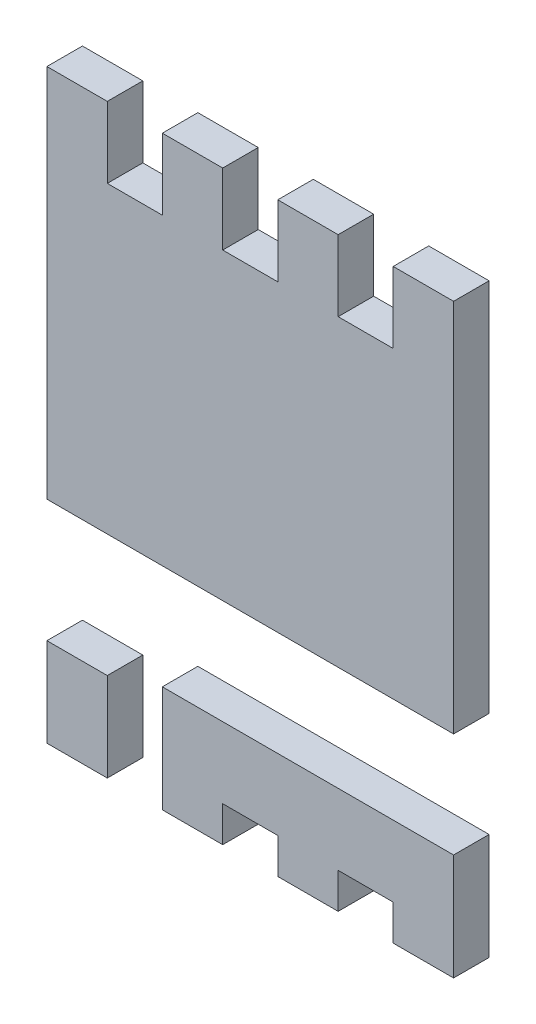
from build123d import *

# Parameters (mm, degrees)
EXTRUDE_1_DEPTH   = 0.2
EXTRUDE_1_2_DEPTH = 0.2
SKETCH_2_W        = 0.34
SKETCH_2_H        = 0.5
EXTRUDE_1_3_DEPTH = 0.2


with BuildPart() as part:
    # Эскиз2 → Бобышка-Вытянуть1 (new body)
    with BuildSketch(Plane.XY):
        Polygon((-1.145, 1.65), (-1.145, -0.46), (1.145, -0.46), (1.145, 1.65), (0.805, 1.65), (0.805, 1.25), (0.495, 1.25), (0.495, 1.65), (0.155, 1.65), (0.155, 1.25), (-0.155, 1.25), (-0.155, 1.65), (-0.495, 1.65), (-0.495, 1.25), (-0.805, 1.25), (-0.805, 1.65), align=None)
    extrude(amount=EXTRUDE_1_DEPTH)


with BuildPart() as body_2:
    # Эскиз2 → Extrude 1 2 (new body)
    with BuildSketch(Plane.XY):
        Polygon((1.145, -1.65), (1.145, -1.05), (-0.495, -1.05), (-0.495, -1.65), (-0.155, -1.65), (-0.155, -1.45), (0.155, -1.45), (0.155, -1.65), (0.495, -1.65), (0.495, -1.45), (0.805, -1.45), (0.805, -1.65), align=None)
    extrude(amount=EXTRUDE_1_2_DEPTH)


with BuildPart() as body_3:
    # Эскиз2 → Extrude 1 3 (new body)
    with BuildSketch(Plane.XY):
        with Locations((-0.975, -1.4)):
            Rectangle(SKETCH_2_W, SKETCH_2_H)
    extrude(amount=EXTRUDE_1_3_DEPTH)


solid = Compound([part.part, body_2.part, body_3.part])
